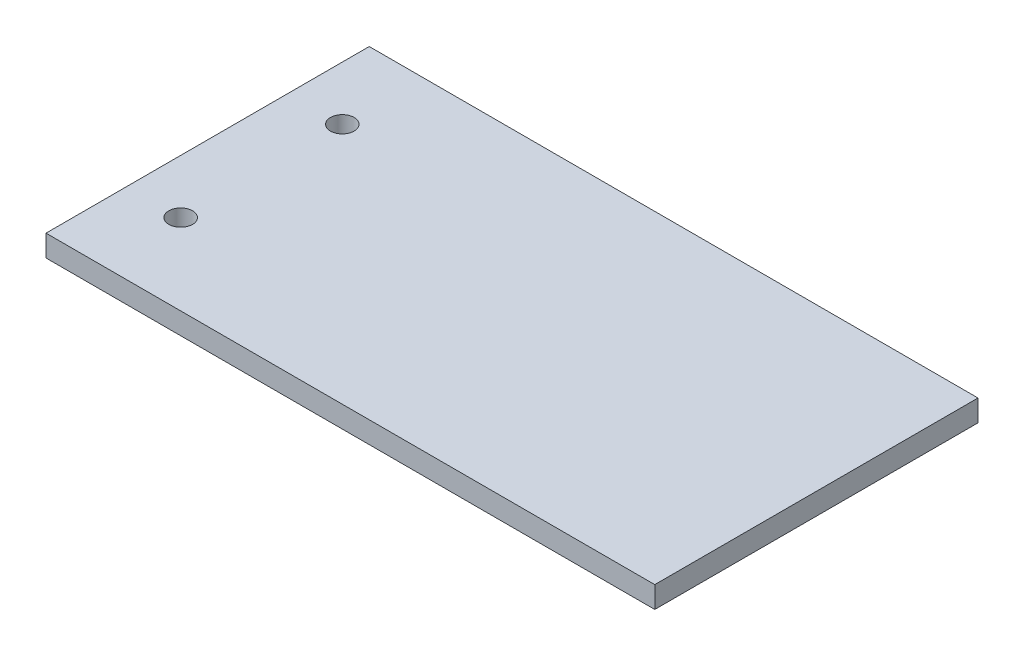
from build123d import *

# Parameters (mm, degrees)
SKETCH1_W           = 113
SKETCH1_H           = 60
SKETCH1_R           = 2.2
BOSS_EXTRUDE1_DEPTH = 4


with BuildPart() as part:
    # Sketch1 → Boss-Extrude1 (new body)
    with BuildSketch(Plane(origin=(0, 0, 0), x_dir=(1, 0, 0), z_dir=(0, 1, 0))):
        with Locations((56.5, 0)):
            Rectangle(SKETCH1_W, SKETCH1_H)
        with Locations((10, 15)):
            Circle(SKETCH1_R, mode=Mode.SUBTRACT)
        with Locations((10, -15)):
            Circle(SKETCH1_R, mode=Mode.SUBTRACT)
    extrude(amount=BOSS_EXTRUDE1_DEPTH)


solid = part.part
